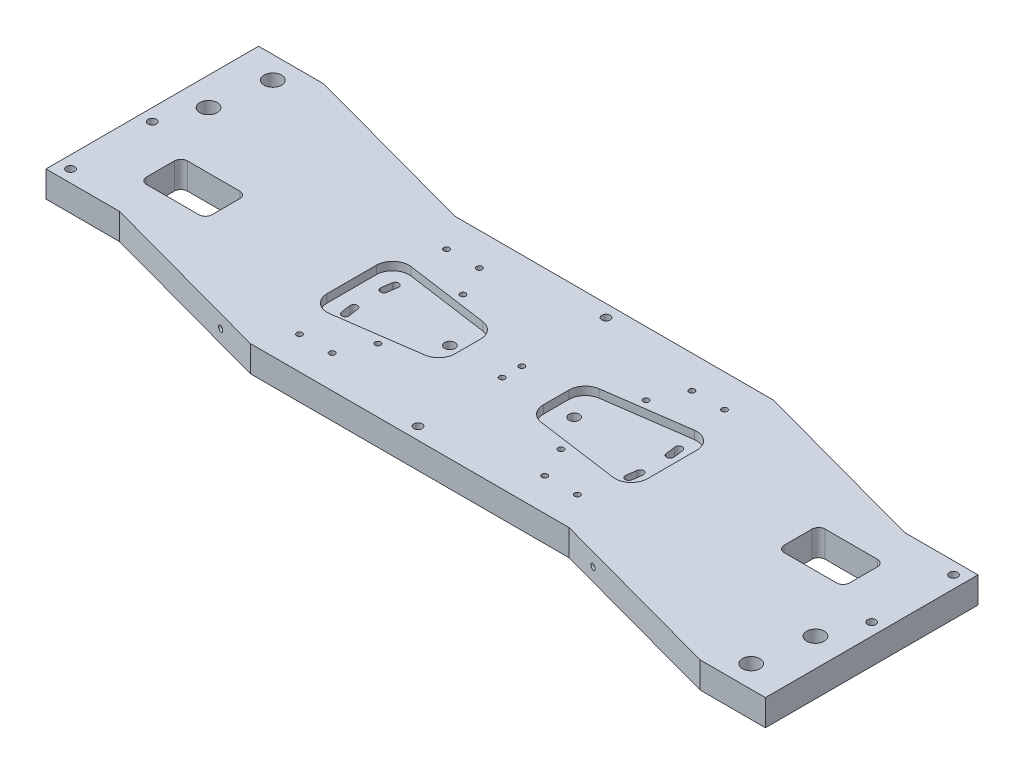
from build123d import *

# Parameters (mm, degrees)
SKETCH1_W                                    = 500
SKETCH1_H                                    = 16
BASE_EXTRUDE_DEPTH                           = 65
EXTRUSION_FOR_BLADE_CLAMPING_DEPTH           = 16
CUTAWAY_TO_BALANCE_BLADE_EXTRUSION_REACH     = 18
HOLES_FOR_WIRES_FROM_BLADES_REACH            = 18
MILLING_FOR_UPPERWIRE_PITCH_ADJUSTMENT_DEPTH = 5
SKETCH9_R                                    = 3.175
SLOTS_HOLE_FOR_UPPERWIRE_PITCH_ADJ_DEPTH     = 16
F_8_32_TAPPED_HOLE1_D                        = 3.4544
F_1_4_20_TAPPED_HOLE1_D                      = 5.1054
F_8_32_TAPPED_HOLE2_D                        = 3.4544
F_8_32_TAPPED_HOLE3_D                        = 3.4544
F_1_4_20_TAPPED_HOLE2_D                      = 5.1054
F_8_32_TAPPED_HOLE5_D                        = 3.4544
F_8_32_TAPPED_HOLE5_DEPTH                    = 12.2936
F_8_32_TAPPED_HOLE5_TIP                      = 1.037806461
F_8_32_TAPPED_HOLE6_D                        = 3.4544
F_8_32_TAPPED_HOLE6_DEPTH                    = 12.2936
F_8_32_TAPPED_HOLE6_TIP                      = 1.037806461
F_8_32_TAPPED_HOLE7_D                        = 3.4544
F_8_32_TAPPED_HOLE7_DEPTH                    = 12.2936
F_8_32_TAPPED_HOLE7_TIP                      = 1.037806461
F_8_32_TAPPED_HOLE8_D                        = 3.4544
F_8_32_TAPPED_HOLE8_DEPTH                    = 12.2936
F_8_32_TAPPED_HOLE8_TIP                      = 1.037806461
F_1_2_13_TAPPED_HOLE4_D                      = 10.71626


with BuildPart() as part:
    # Sketch1 → Base-Extrude (new body, symmetric)
    with BuildSketch(Plane.XY):
        with Locations((0, -8)):
            Rectangle(SKETCH1_W, SKETCH1_H)
    extrude(amount=BASE_EXTRUDE_DEPTH, both=True)

    # Sketch3 → Extrusion for Blade Clamping (add)
    with BuildSketch(Plane(origin=(0, 0, 0), x_dir=(-1, 0, 0), z_dir=(0, 1, 0))):
        Polygon((-210, 95), (-100, 65), (-250, 65), (-250, 95), align=None)
        Polygon((210, -95), (100, -65), (250, -65), (250, -95), align=None)
    extrude(amount=-EXTRUSION_FOR_BLADE_CLAMPING_DEPTH)

    # Sketch4 → Cutaway to Balance Blade Extrusion (cut, up to next)
    with BuildSketch(Plane(origin=(0, 0, 0), x_dir=(-1, 0, 0), z_dir=(0, 1, 0)), mode=Mode.PRIVATE) as cutaway_to_balance_blade_extrusion_sk1:
        Polygon((-205, -35), (-95, -65), (-250, -65), (-250, -35), align=None)
    cutaway_to_balance_blade_extrusion_tool1 = extrude(cutaway_to_balance_blade_extrusion_sk1.sketch, amount=-CUTAWAY_TO_BALANCE_BLADE_EXTRUSION_REACH, mode=Mode.PRIVATE) & part.part
    add(cutaway_to_balance_blade_extrusion_tool1.solids().sort_by_distance((194.958333, 0, -52.75))[0], mode=Mode.SUBTRACT)
    # Sketch4 → Cutaway to Balance Blade Extrusion (cut, up to next)
    with BuildSketch(Plane(origin=(0, 0, 0), x_dir=(-1, 0, 0), z_dir=(0, 1, 0)), mode=Mode.PRIVATE) as cutaway_to_balance_blade_extrusion_sk2:
        Polygon((250, 65), (250, 35), (205, 35), (95, 65), align=None)
    cutaway_to_balance_blade_extrusion_tool2 = extrude(cutaway_to_balance_blade_extrusion_sk2.sketch, amount=-CUTAWAY_TO_BALANCE_BLADE_EXTRUSION_REACH, mode=Mode.PRIVATE) & part.part
    add(cutaway_to_balance_blade_extrusion_tool2.solids().sort_by_distance((-194.958333, 0, 52.75))[0], mode=Mode.SUBTRACT)

    # Sketch5 → Holes for Wires from Blades (cut, up to next)
    with BuildSketch(Plane(origin=(0, 0, 0), x_dir=(-1, 0, 0), z_dir=(0, 1, 0)), mode=Mode.PRIVATE) as holes_for_wires_from_blades_sk1:
        with BuildLine():
            Line((-215, 8.5), (-215, -8.5))
            ThreePointArc((-215, -8.5), (-213.828427125, -11.328427125), (-211, -12.5))
            Line((-211, -12.5), (-179, -12.5))
            ThreePointArc((-179, -12.5), (-176.171572875, -11.328427125), (-175, -8.5))
            Line((-175, -8.5), (-175, 8.5))
            ThreePointArc((-175, 8.5), (-176.171572875, 11.328427125), (-179, 12.5))
            Line((-179, 12.5), (-211, 12.5))
            ThreePointArc((-211, 12.5), (-213.828427125, 11.328427125), (-215, 8.5))
        make_face()
    holes_for_wires_from_blades_tool1 = extrude(holes_for_wires_from_blades_sk1.sketch, amount=-HOLES_FOR_WIRES_FROM_BLADES_REACH, mode=Mode.PRIVATE) & part.part
    add(holes_for_wires_from_blades_tool1.solids().sort_by_distance((195, 0, 0))[0], mode=Mode.SUBTRACT)
    # Sketch5 → Holes for Wires from Blades (cut, up to next)
    with BuildSketch(Plane(origin=(0, 0, 0), x_dir=(-1, 0, 0), z_dir=(0, 1, 0)), mode=Mode.PRIVATE) as holes_for_wires_from_blades_sk2:
        with BuildLine():
            Line((211, 12.5), (179, 12.5))
            ThreePointArc((179, 12.5), (176.171572875, 11.328427125), (175, 8.5))
            Line((175, 8.5), (175, -8.5))
            ThreePointArc((175, -8.5), (176.171572875, -11.328427125), (179, -12.5))
            Line((179, -12.5), (211, -12.5))
            ThreePointArc((211, -12.5), (213.828427125, -11.328427125), (215, -8.5))
            Line((215, -8.5), (215, 8.5))
            ThreePointArc((215, 8.5), (213.828427125, 11.328427125), (211, 12.5))
        make_face()
    holes_for_wires_from_blades_tool2 = extrude(holes_for_wires_from_blades_sk2.sketch, amount=-HOLES_FOR_WIRES_FROM_BLADES_REACH, mode=Mode.PRIVATE) & part.part
    add(holes_for_wires_from_blades_tool2.solids().sort_by_distance((-195, 0, 0))[0], mode=Mode.SUBTRACT)

    # Sketch7 → Milling for UpperWire Pitch Adjustment (cut)
    with BuildSketch(Plane(origin=(0, 0, 0), x_dir=(-1, 0, 0), z_dir=(0, 1, 0))):
        with BuildLine():
            Line((-27, -7.83241743), (-27, 7.83241743))
            ThreePointArc((-27, 7.83241743), (-29.452904198, 14.39300772), (-35.60826899, 17.735098118))
            Line((-35.60826899, 17.735098118), (-86.60826899, 24.902680687))
            ThreePointArc((-86.60826899, 24.902680687), (-94.56059029, 22.547095802), (-98, 15))
            Line((-98, 15), (-98, -15))
            ThreePointArc((-98, -15), (-94.56059029, -22.547095802), (-86.60826899, -24.902680687))
            Line((-86.60826899, -24.902680687), (-35.60826899, -17.735098118))
            ThreePointArc((-35.60826899, -17.735098118), (-29.452904198, -14.39300772), (-27, -7.83241743))
        make_face()
        with BuildLine():
            Line((86.60826899, -24.902680687), (35.60826899, -17.735098118))
            ThreePointArc((35.60826899, -17.735098118), (29.452904198, -14.39300772), (27, -7.83241743))
            Line((27, -7.83241743), (27, 7.83241743))
            ThreePointArc((27, 7.83241743), (29.452904198, 14.39300772), (35.60826899, 17.735098118))
            Line((35.60826899, 17.735098118), (86.60826899, 24.902680687))
            ThreePointArc((86.60826899, 24.902680687), (94.56059029, 22.547095802), (98, 15))
            Line((98, 15), (98, -15))
            ThreePointArc((98, -15), (94.56059029, -22.547095802), (86.60826899, -24.902680687))
        make_face()
    extrude(amount=-MILLING_FOR_UPPERWIRE_PITCH_ADJUSTMENT_DEPTH, mode=Mode.SUBTRACT)

    # Sketch9 → Slots/Hole for UpperWire Pitch Adj (cut)
    with BuildSketch(Plane(origin=(0, 0, 0), x_dir=(-1, 0, 0), z_dir=(0, 1, 0))):
        with Locations((38, 0)):
            Circle(SKETCH9_R)
        with Locations((-38, 0)):
            Circle(SKETCH9_R)
        with BuildLine():
            ThreePointArc((-88.783028675, -15.654843384), (-86.289278515, -17.400986044), (-84.543135856, -14.907235885))
            ThreePointArc((-84.543135856, -14.907235885), (-85.011889491, -11.947641909), (-85.377069234, -8.973491571))
            ThreePointArc((-85.377069234, -8.973491571), (-87.742939989, -7.057647209), (-89.65878435, -9.423517964))
            ThreePointArc((-89.65878435, -9.423517964), (-89.275290607, -12.54682386), (-88.783028675, -15.654843384))
        make_face()
        with BuildLine():
            ThreePointArc((-84.543135856, 14.907235885), (-86.289278515, 17.400986044), (-88.783028675, 15.654843384))
            ThreePointArc((-88.783028675, 15.654843384), (-89.275290607, 12.54682386), (-89.65878435, 9.423517964))
            ThreePointArc((-89.65878435, 9.423517964), (-87.742939989, 7.057647209), (-85.377069234, 8.973491571))
            ThreePointArc((-85.377069234, 8.973491571), (-85.011889491, 11.947641909), (-84.543135856, 14.907235885))
        make_face()
        with BuildLine():
            ThreePointArc((88.783028675, 15.654843384), (89.275290607, 12.54682386), (89.65878435, 9.423517964))
            ThreePointArc((89.65878435, 9.423517964), (87.742939989, 7.057647209), (85.377069234, 8.973491571))
            ThreePointArc((85.377069234, 8.973491571), (85.011889491, 11.947641909), (84.543135856, 14.907235885))
            ThreePointArc((84.543135856, 14.907235885), (86.289278515, 17.400986044), (88.783028675, 15.654843384))
        make_face()
        with BuildLine():
            ThreePointArc((85.377069234, -8.973491571), (85.011889491, -11.947641909), (84.543135856, -14.907235885))
            ThreePointArc((84.543135856, -14.907235885), (86.289278515, -17.400986044), (88.783028675, -15.654843384))
            ThreePointArc((88.783028675, -15.654843384), (89.275290607, -12.54682386), (89.65878435, -9.423517964))
            ThreePointArc((89.65878435, -9.423517964), (87.742939989, -7.057647209), (85.377069234, -8.973491571))
        make_face()
    extrude(amount=-SLOTS_HOLE_FOR_UPPERWIRE_PITCH_ADJ_DEPTH, mode=Mode.SUBTRACT)

    # #8-32 Tapped Hole1 (through all)
    with Locations(Plane(origin=(0, 0, 6), x_dir=(1, 0, 0), z_dir=(0, 1, 0))):
        with Locations((0, 0), (0, 12)):
            Hole(F_8_32_TAPPED_HOLE1_D / 2)

    # 1/4-20 Tapped Hole1 (through all)
    with Locations(Plane(origin=(0, 0, 0), x_dir=(-1, 0, 0), z_dir=(0, 1, 0))):
        with Locations((-242.5, -27.5), (-242.5, 22.5), (242.5, 27.5), (242.5, -22.5)):
            Hole(F_1_4_20_TAPPED_HOLE1_D / 2)

    # #8-32 Tapped Hole2 (through all)
    with Locations(Plane(origin=(0, 0, 0), x_dir=(-1, 0, 0), z_dir=(0, 1, 0))):
        with Locations((-65, 45), (-85, 45), (85, 45), (65, 45), (85, -45), (65, -45), (-65, -45), (-85, -45)):
            Hole(F_8_32_TAPPED_HOLE2_D / 2)

    # #8-32 Tapped Hole3 (through all)
    with Locations(Plane.XZ.offset(16)):
        with Locations((-56, 26), (56, -26), (56, 26), (-56, -26)):
            Hole(F_8_32_TAPPED_HOLE3_D / 2)

    # 1/4-20 Tapped Hole2 (through all)
    with Locations(Plane(origin=(0, 0, 0), x_dir=(-1, 0, 0), z_dir=(0, 1, 0))):
        with Locations((0, 57.5), (0, -57.5)):
            Hole(F_1_4_20_TAPPED_HOLE2_D / 2)

    # #8-32 Tapped Hole5
    with Locations(Plane.XY.offset(59.7)):
        with Locations((-120, -8)):
            Hole(F_8_32_TAPPED_HOLE5_D / 2, depth=F_8_32_TAPPED_HOLE5_DEPTH)
            with Locations((0, 0, -(F_8_32_TAPPED_HOLE5_DEPTH + F_8_32_TAPPED_HOLE5_TIP / 2))):  # 118° drill point
                Cone(0, F_8_32_TAPPED_HOLE5_D / 2, F_8_32_TAPPED_HOLE5_TIP, mode=Mode.SUBTRACT)

    # #8-32 Tapped Hole6
    with Locations(Plane.XY.offset(71)):
        with Locations((120, -8)):
            Hole(F_8_32_TAPPED_HOLE6_D / 2, depth=F_8_32_TAPPED_HOLE6_DEPTH)
            with Locations((0, 0, -(F_8_32_TAPPED_HOLE6_DEPTH + F_8_32_TAPPED_HOLE6_TIP / 2))):  # 118° drill point
                Cone(0, F_8_32_TAPPED_HOLE6_D / 2, F_8_32_TAPPED_HOLE6_TIP, mode=Mode.SUBTRACT)

    # #8-32 Tapped Hole7
    with Locations(Plane(origin=(0, 0, -59.7), x_dir=(-1, 0, 0), z_dir=(0, 0, -1))):
        with Locations((-120, -8)):
            Hole(F_8_32_TAPPED_HOLE7_D / 2, depth=F_8_32_TAPPED_HOLE7_DEPTH)
            with Locations((0, 0, -(F_8_32_TAPPED_HOLE7_DEPTH + F_8_32_TAPPED_HOLE7_TIP / 2))):  # 118° drill point
                Cone(0, F_8_32_TAPPED_HOLE7_D / 2, F_8_32_TAPPED_HOLE7_TIP, mode=Mode.SUBTRACT)

    # #8-32 Tapped Hole8
    with Locations(Plane(origin=(0, 0, -71), x_dir=(-1, 0, 0), z_dir=(0, 0, -1))):
        with Locations((120, -8)):
            Hole(F_8_32_TAPPED_HOLE8_D / 2, depth=F_8_32_TAPPED_HOLE8_DEPTH)
            with Locations((0, 0, -(F_8_32_TAPPED_HOLE8_DEPTH + F_8_32_TAPPED_HOLE8_TIP / 2))):  # 118° drill point
                Cone(0, F_8_32_TAPPED_HOLE8_D / 2, F_8_32_TAPPED_HOLE8_TIP, mode=Mode.SUBTRACT)

    # 1/2-13 Tapped Hole4 (through all)
    with Locations(Plane(origin=(-232.778633851, 0, -47.189591945), x_dir=(0, 0, 1), z_dir=(0, 1, 0))):
        with Locations((0, 0), (-34.215003793, 5.113466578), (94.37918389, 465.557267702), (128.594187683, 460.443801124)):
            Hole(F_1_2_13_TAPPED_HOLE4_D / 2)


solid = part.part
